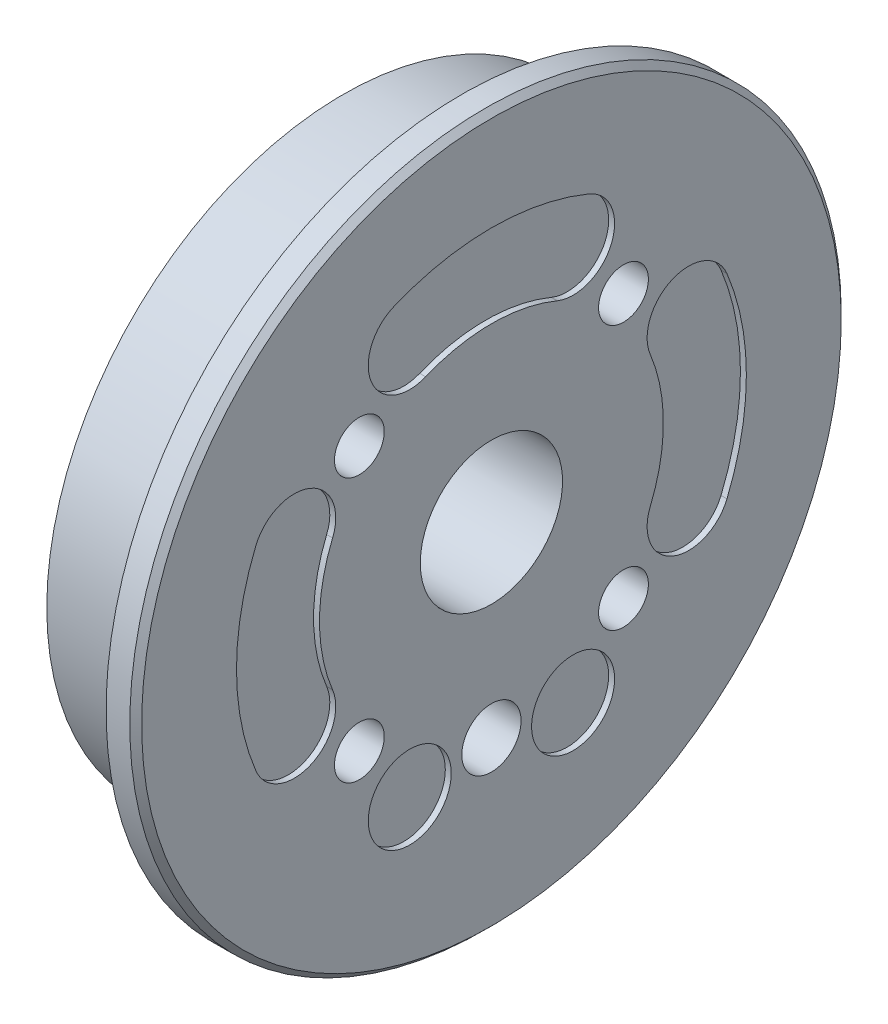
from build123d import *

# Parameters (mm, degrees)
SKETCH1_W                      = 2.5
SKETCH1_H                      = 30
SKETCH2_R                      = 25
BOSS_EXTRUDE1_DEPTH            = 10
CUT_EXTRUDE1_DEPTH             = 0.5
CUT_EXTRUDE2_DEPTH             = 0.5
CUT_EXTRUDE3_DEPTH             = 0.5
F_12_0_12_DIAMETER_HOLE1_D     = 12
F_12_0_12_DIAMETER_HOLE1_DEPTH = 12.5
F_7_0_7_DIAMETER_HOLE1_D       = 7
F_7_0_7_DIAMETER_HOLE1_DEPTH   = 0.5
F_4_2_4_2_DIAMETER_HOLE1_D     = 4.2
F_4_2_4_2_DIAMETER_HOLE1_DEPTH = 12.5
F_5_0_5_DIAMETER_HOLE1_D       = 5
F_5_0_5_DIAMETER_HOLE1_DEPTH   = 7
CHAMFER1_SIZE                  = 0.5


with BuildPart() as part:
    # Sketch1 → Revolve1 (revolve)
    with BuildSketch(Plane.XY):
        with Locations((11.25, 15)):
            Rectangle(SKETCH1_W, SKETCH1_H)
    revolve(axis=Axis((10, 0, 0), (1, 0, 0)))

    # Sketch2 → Boss-Extrude1 (add)
    with BuildSketch(Plane.ZY.offset(-10)):
        Circle(SKETCH2_R)
    extrude(amount=BOSS_EXTRUDE1_DEPTH)

    # Sketch3 → Cut-Extrude1 (cut)
    with BuildSketch(Plane(origin=(12.5, 0, 0), x_dir=(0, 0, -1), z_dir=(1, 0, 0))):
        with BuildLine():
            ThreePointArc((13.396253221, 5.548909769), (14.5, 0), (13.396253221, -5.548909769))
            ThreePointArc((13.396253221, -5.548909769), (15.290439572, -10.121880146), (19.863409949, -8.227693796))
            ThreePointArc((19.863409949, -8.227693796), (21.5, 0), (19.863409949, 8.227693796))
            ThreePointArc((19.863409949, 8.227693796), (15.290439572, 10.121880146), (13.396253221, 5.548909769))
        make_face()
    extrude(amount=-CUT_EXTRUDE1_DEPTH, mode=Mode.SUBTRACT)

    # Sketch4 → Cut-Extrude2 (cut)
    with BuildSketch(Plane(origin=(12.5, 0, 0), x_dir=(0, 0, -1), z_dir=(1, 0, 0))):
        with BuildLine():
            ThreePointArc((-5.548909769, 13.396253221), (0, 14.5), (5.548909769, 13.396253221))
            ThreePointArc((5.548909769, 13.396253221), (10.121880146, 15.290439572), (8.227693796, 19.863409949))
            ThreePointArc((8.227693796, 19.863409949), (0, 21.5), (-8.227693796, 19.863409949))
            ThreePointArc((-8.227693796, 19.863409949), (-10.121880146, 15.290439572), (-5.548909769, 13.396253221))
        make_face()
    extrude(amount=-CUT_EXTRUDE2_DEPTH, mode=Mode.SUBTRACT)

    # Sketch5 → Cut-Extrude3 (cut)
    with BuildSketch(Plane(origin=(12.5, 0, 0), x_dir=(0, 0, -1), z_dir=(1, 0, 0))):
        with BuildLine():
            ThreePointArc((-13.396253221, -5.548909769), (-14.5, 0), (-13.396253221, 5.548909769))
            ThreePointArc((-13.396253221, 5.548909769), (-15.290439572, 10.121880146), (-19.863409949, 8.227693796))
            ThreePointArc((-19.863409949, 8.227693796), (-21.5, 0), (-19.863409949, -8.227693796))
            ThreePointArc((-19.863409949, -8.227693796), (-15.290439572, -10.121880146), (-13.396253221, -5.548909769))
        make_face()
    extrude(amount=-CUT_EXTRUDE3_DEPTH, mode=Mode.SUBTRACT)

    # Ø12.0 (12) Diameter Hole1
    with Locations(Plane.ZY):
        with Locations((0, 0)):
            Hole(F_12_0_12_DIAMETER_HOLE1_D / 2, depth=F_12_0_12_DIAMETER_HOLE1_DEPTH)

    # Ø7.0 (7) Diameter Hole1
    with Locations(Plane(origin=(12.5, 0, 0), x_dir=(0, 0, -1), z_dir=(1, 0, 0))):
        with Locations((-6.888301783, -16.629831585), (6.888301783, -16.629831585)):
            Hole(F_7_0_7_DIAMETER_HOLE1_D / 2, depth=F_7_0_7_DIAMETER_HOLE1_DEPTH)

    # Ø4.2 (4.2) Diameter Hole1
    with Locations(Plane.ZY):
        with Locations((-11.136931804, -11.136931804), (-11.136931804, 11.136931804), (11.136931804, 11.136931804), (11.136931804, -11.136931804)):
            Hole(F_4_2_4_2_DIAMETER_HOLE1_D / 2, depth=F_4_2_4_2_DIAMETER_HOLE1_DEPTH)

    # Ø5.0 (5) Diameter Hole1
    with Locations(Plane(origin=(12.5, 0, 0), x_dir=(0, 0, -1), z_dir=(1, 0, 0))):
        with Locations((0, -15.75)):
            Hole(F_5_0_5_DIAMETER_HOLE1_D / 2, depth=F_5_0_5_DIAMETER_HOLE1_DEPTH)

    # Chamfer1
    chamfer1_edges = [part.edges().sort_by_distance(p)[0] for p in [
        (12.5, -30, 0),
    ]]
    chamfer(chamfer1_edges, length=CHAMFER1_SIZE)


solid = part.part
